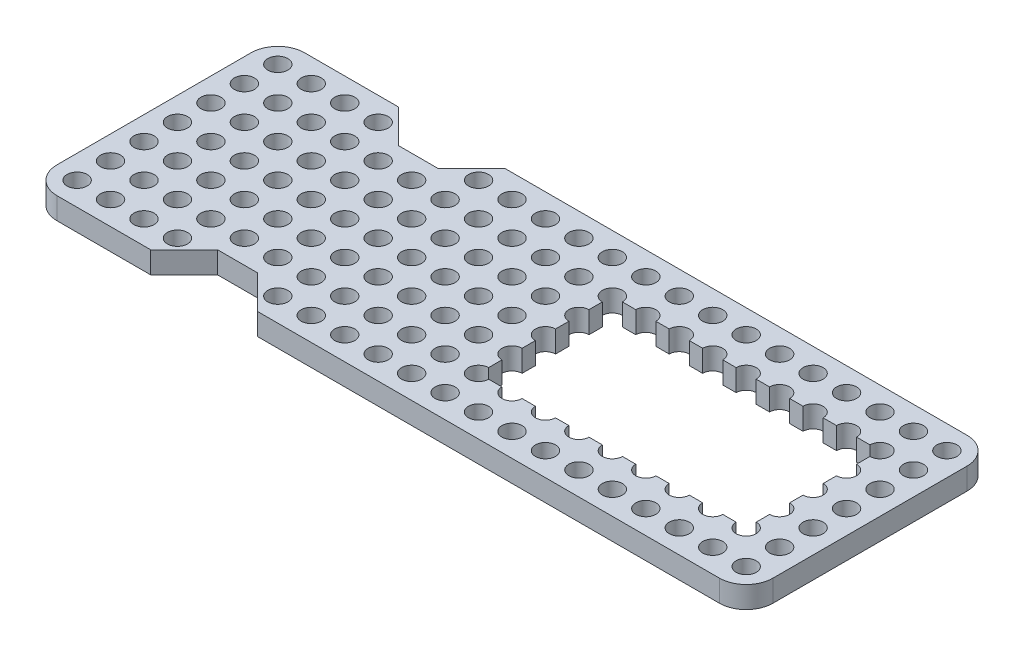
from build123d import *

# Parameters (mm, degrees)
SKETCH1_R           = 1.5025
BOSS_EXTRUDE1_DEPTH = 3.25


with BuildPart() as part:
    # Sketch1 → Boss-Extrude1 (new body)
    with BuildSketch(Plane(origin=(0, 0, 0), x_dir=(1, 0, 0), z_dir=(0, 1, 0))):
        with BuildLine():
            Line((-35.5, 18.5), (-49.5, 18.5))
            ThreePointArc((-49.5, 18.5), (-52.328427125, 17.328427125), (-53.5, 14.5))
            Line((-53.5, 14.5), (-53.5, -14.5))
            ThreePointArc((-53.5, -14.5), (-52.328427125, -17.328427125), (-49.5, -18.5))
            Line((-49.5, -18.5), (-35.5, -18.5))
            Line((-35.5, -18.5), (-30.5, -13.5))
            Line((-30.5, -13.5), (-24.913361383, -13.5))
            Line((-24.913361383, -13.5), (-24.5, -13.5))
            Line((-24.5, -13.5), (-24.358821857, -13.641178143))
            Line((-24.358821857, -13.641178143), (-19.5, -18.5))
            Line((-19.5, -18.5), (49.5, -18.5))
            ThreePointArc((49.5, -18.5), (52.328427125, -17.328427125), (53.5, -14.5))
            Line((53.5, -14.5), (53.5, 14.5))
            ThreePointArc((53.5, 14.5), (52.328427125, 17.328427125), (49.5, 18.5))
            Line((49.5, 18.5), (-19.5, 18.5))
            Line((-19.5, 18.5), (-24.358821857, 13.641178143))
            Line((-24.358821857, 13.641178143), (-24.5, 13.5))
            Line((-24.5, 13.5), (-24.913361383, 13.5))
            Line((-24.913361383, 13.5), (-30.086638617, 13.5))
            Line((-30.086638617, 13.5), (-30.5, 13.5))
            Line((-30.5, 13.5), (-30.641178143, 13.641178143))
            Line((-30.641178143, 13.641178143), (-35.5, 18.5))
        make_face()
        with Locations((-50, -15)):
            Circle(SKETCH1_R, mode=Mode.SUBTRACT)
        with Locations((-45, -15)):
            Circle(SKETCH1_R, mode=Mode.SUBTRACT)
        with Locations((-40, -15)):
            Circle(SKETCH1_R, mode=Mode.SUBTRACT)
        with Locations((-35, -15)):
            Circle(SKETCH1_R, mode=Mode.SUBTRACT)
        with Locations((-50, -10)):
            Circle(SKETCH1_R, mode=Mode.SUBTRACT)
        with Locations((-45, -10)):
            Circle(SKETCH1_R, mode=Mode.SUBTRACT)
        with Locations((-40, -10)):
            Circle(SKETCH1_R, mode=Mode.SUBTRACT)
        with Locations((-35, -10)):
            Circle(SKETCH1_R, mode=Mode.SUBTRACT)
        with Locations((-30, -10)):
            Circle(SKETCH1_R, mode=Mode.SUBTRACT)
        with Locations((-20, -15)):
            Circle(SKETCH1_R, mode=Mode.SUBTRACT)
        with Locations((-15, -15)):
            Circle(SKETCH1_R, mode=Mode.SUBTRACT)
        with Locations((-10, -15)):
            Circle(SKETCH1_R, mode=Mode.SUBTRACT)
        with Locations((-5, -15)):
            Circle(SKETCH1_R, mode=Mode.SUBTRACT)
        with Locations((-25, -10)):
            Circle(SKETCH1_R, mode=Mode.SUBTRACT)
        with Locations((-20, -10)):
            Circle(SKETCH1_R, mode=Mode.SUBTRACT)
        with Locations((-15, -10)):
            Circle(SKETCH1_R, mode=Mode.SUBTRACT)
        with Locations((-10, -10)):
            Circle(SKETCH1_R, mode=Mode.SUBTRACT)
        with Locations((-5, -10)):
            Circle(SKETCH1_R, mode=Mode.SUBTRACT)
        with Locations((0, -10)):
            Circle(SKETCH1_R, mode=Mode.SUBTRACT)
        with Locations((-50, -5)):
            Circle(SKETCH1_R, mode=Mode.SUBTRACT)
        with Locations((-45, -5)):
            Circle(SKETCH1_R, mode=Mode.SUBTRACT)
        with Locations((-40, -5)):
            Circle(SKETCH1_R, mode=Mode.SUBTRACT)
        with Locations((-35, -5)):
            Circle(SKETCH1_R, mode=Mode.SUBTRACT)
        with Locations((-30, -5)):
            Circle(SKETCH1_R, mode=Mode.SUBTRACT)
        with Locations((-25, -5)):
            Circle(SKETCH1_R, mode=Mode.SUBTRACT)
        with Locations((-20, -5)):
            Circle(SKETCH1_R, mode=Mode.SUBTRACT)
        with Locations((-15, -5)):
            Circle(SKETCH1_R, mode=Mode.SUBTRACT)
        with Locations((-10, -5)):
            Circle(SKETCH1_R, mode=Mode.SUBTRACT)
        with Locations((-5, -5)):
            Circle(SKETCH1_R, mode=Mode.SUBTRACT)
        with Locations((0, -5)):
            Circle(SKETCH1_R, mode=Mode.SUBTRACT)
        with Locations((0, -15)):
            Circle(SKETCH1_R, mode=Mode.SUBTRACT)
        with Locations((5, -15)):
            Circle(SKETCH1_R, mode=Mode.SUBTRACT)
        with Locations((10, -15)):
            Circle(SKETCH1_R, mode=Mode.SUBTRACT)
        with Locations((15, -15)):
            Circle(SKETCH1_R, mode=Mode.SUBTRACT)
        with Locations((20, -15)):
            Circle(SKETCH1_R, mode=Mode.SUBTRACT)
        with Locations((25, -15)):
            Circle(SKETCH1_R, mode=Mode.SUBTRACT)
        with Locations((30, -15)):
            Circle(SKETCH1_R, mode=Mode.SUBTRACT)
        with Locations((35, -15)):
            Circle(SKETCH1_R, mode=Mode.SUBTRACT)
        with Locations((40, -15)):
            Circle(SKETCH1_R, mode=Mode.SUBTRACT)
        with Locations((45, -15)):
            Circle(SKETCH1_R, mode=Mode.SUBTRACT)
        with Locations((50, -15)):
            Circle(SKETCH1_R, mode=Mode.SUBTRACT)
        with Locations((50, -10)):
            Circle(SKETCH1_R, mode=Mode.SUBTRACT)
        with Locations((50, -5)):
            Circle(SKETCH1_R, mode=Mode.SUBTRACT)
        with Locations((-50, 0)):
            Circle(SKETCH1_R, mode=Mode.SUBTRACT)
        with Locations((-45, 0)):
            Circle(SKETCH1_R, mode=Mode.SUBTRACT)
        with Locations((-40, 0)):
            Circle(SKETCH1_R, mode=Mode.SUBTRACT)
        with Locations((-35, 0)):
            Circle(SKETCH1_R, mode=Mode.SUBTRACT)
        with Locations((-30, 0)):
            Circle(SKETCH1_R, mode=Mode.SUBTRACT)
        with Locations((-50, 5)):
            Circle(SKETCH1_R, mode=Mode.SUBTRACT)
        with Locations((-45, 5)):
            Circle(SKETCH1_R, mode=Mode.SUBTRACT)
        with Locations((-40, 5)):
            Circle(SKETCH1_R, mode=Mode.SUBTRACT)
        with Locations((-35, 5)):
            Circle(SKETCH1_R, mode=Mode.SUBTRACT)
        with Locations((-30, 5)):
            Circle(SKETCH1_R, mode=Mode.SUBTRACT)
        with Locations((-25, 0)):
            Circle(SKETCH1_R, mode=Mode.SUBTRACT)
        with Locations((-20, 0)):
            Circle(SKETCH1_R, mode=Mode.SUBTRACT)
        with Locations((-15, 0)):
            Circle(SKETCH1_R, mode=Mode.SUBTRACT)
        with Locations((-10, 0)):
            Circle(SKETCH1_R, mode=Mode.SUBTRACT)
        with Locations((-5, 0)):
            Circle(SKETCH1_R, mode=Mode.SUBTRACT)
        Circle(SKETCH1_R, mode=Mode.SUBTRACT)
        with Locations((-25, 5)):
            Circle(SKETCH1_R, mode=Mode.SUBTRACT)
        with Locations((-20, 5)):
            Circle(SKETCH1_R, mode=Mode.SUBTRACT)
        with Locations((-15, 5)):
            Circle(SKETCH1_R, mode=Mode.SUBTRACT)
        with Locations((-10, 5)):
            Circle(SKETCH1_R, mode=Mode.SUBTRACT)
        with Locations((-5, 5)):
            Circle(SKETCH1_R, mode=Mode.SUBTRACT)
        with Locations((0, 5)):
            Circle(SKETCH1_R, mode=Mode.SUBTRACT)
        with Locations((-50, 10)):
            Circle(SKETCH1_R, mode=Mode.SUBTRACT)
        with Locations((-45, 10)):
            Circle(SKETCH1_R, mode=Mode.SUBTRACT)
        with Locations((-40, 10)):
            Circle(SKETCH1_R, mode=Mode.SUBTRACT)
        with Locations((-35, 10)):
            Circle(SKETCH1_R, mode=Mode.SUBTRACT)
        with Locations((-30, 10)):
            Circle(SKETCH1_R, mode=Mode.SUBTRACT)
        with Locations((-50, 15)):
            Circle(SKETCH1_R, mode=Mode.SUBTRACT)
        with Locations((-45, 15)):
            Circle(SKETCH1_R, mode=Mode.SUBTRACT)
        with Locations((-40, 15)):
            Circle(SKETCH1_R, mode=Mode.SUBTRACT)
        with Locations((-35, 15)):
            Circle(SKETCH1_R, mode=Mode.SUBTRACT)
        with Locations((-25, 10)):
            Circle(SKETCH1_R, mode=Mode.SUBTRACT)
        with Locations((-20, 10)):
            Circle(SKETCH1_R, mode=Mode.SUBTRACT)
        with Locations((-15, 10)):
            Circle(SKETCH1_R, mode=Mode.SUBTRACT)
        with Locations((-10, 10)):
            Circle(SKETCH1_R, mode=Mode.SUBTRACT)
        with Locations((-5, 10)):
            Circle(SKETCH1_R, mode=Mode.SUBTRACT)
        with Locations((0, 10)):
            Circle(SKETCH1_R, mode=Mode.SUBTRACT)
        with Locations((-20, 15)):
            Circle(SKETCH1_R, mode=Mode.SUBTRACT)
        with Locations((-15, 15)):
            Circle(SKETCH1_R, mode=Mode.SUBTRACT)
        with Locations((-10, 15)):
            Circle(SKETCH1_R, mode=Mode.SUBTRACT)
        with Locations((-5, 15)):
            Circle(SKETCH1_R, mode=Mode.SUBTRACT)
        with Locations((0, 15)):
            Circle(SKETCH1_R, mode=Mode.SUBTRACT)
        with BuildLine():
            Line((45, -6.5025), (45, -8.4975))
            ThreePointArc((45, -8.4975), (46.062427939, -11.062427939), (43.4975, -10))
            Line((43.4975, -10), (41.5025, -10))
            ThreePointArc((41.5025, -10), (40, -11.5025), (38.4975, -10))
            Line((38.4975, -10), (36.5025, -10))
            ThreePointArc((36.5025, -10), (35, -11.5025), (33.4975, -10))
            Line((33.4975, -10), (31.5025, -10))
            ThreePointArc((31.5025, -10), (30, -11.5025), (28.4975, -10))
            Line((28.4975, -10), (26.5025, -10))
            ThreePointArc((26.5025, -10), (25, -11.5025), (23.4975, -10))
            Line((23.4975, -10), (21.5025, -10))
            ThreePointArc((21.5025, -10), (20, -11.5025), (18.4975, -10))
            Line((18.4975, -10), (16.5025, -10))
            ThreePointArc((16.5025, -10), (15, -11.5025), (13.4975, -10))
            Line((13.4975, -10), (11.5025, -10))
            ThreePointArc((11.5025, -10), (10, -11.5025), (8.4975, -10))
            Line((8.4975, -10), (6.5025, -10))
            ThreePointArc((6.5025, -10), (3.937572061, -11.062427939), (5, -8.4975))
            Line((5, -8.4975), (5, -6.5025))
            ThreePointArc((5, -6.5025), (3.4975, -5), (5, -3.4975))
            Line((5, -3.4975), (5, -1.5025))
            ThreePointArc((5, -1.5025), (3.4975, 0), (5, 1.5025))
            Line((5, 1.5025), (5, 3.4975))
            ThreePointArc((5, 3.4975), (3.4975, 5), (5, 6.5025))
            Line((5, 6.5025), (5, 8.4975))
            ThreePointArc((5, 8.4975), (3.937572061, 11.062427939), (6.5025, 10))
            Line((6.5025, 10), (8.4975, 10))
            ThreePointArc((8.4975, 10), (10, 11.5025), (11.5025, 10))
            Line((11.5025, 10), (13.4975, 10))
            ThreePointArc((13.4975, 10), (15, 11.5025), (16.5025, 10))
            Line((16.5025, 10), (18.4975, 10))
            ThreePointArc((18.4975, 10), (20, 11.5025), (21.5025, 10))
            Line((21.5025, 10), (23.4975, 10))
            ThreePointArc((23.4975, 10), (25, 11.5025), (26.5025, 10))
            Line((26.5025, 10), (28.4975, 10))
            ThreePointArc((28.4975, 10), (30, 11.5025), (31.5025, 10))
            Line((31.5025, 10), (33.4975, 10))
            ThreePointArc((33.4975, 10), (35, 11.5025), (36.5025, 10))
            Line((36.5025, 10), (38.4975, 10))
            ThreePointArc((38.4975, 10), (40, 11.5025), (41.5025, 10))
            Line((41.5025, 10), (43.4975, 10))
            ThreePointArc((43.4975, 10), (46.062427939, 11.062427939), (45, 8.4975))
            Line((45, 8.4975), (45, 6.5025))
            ThreePointArc((45, 6.5025), (46.5025, 5), (45, 3.4975))
            Line((45, 3.4975), (45, 1.5025))
            ThreePointArc((45, 1.5025), (46.5025, 0), (45, -1.5025))
            Line((45, -1.5025), (45, -3.4975))
            ThreePointArc((45, -3.4975), (46.5025, -5), (45, -6.5025))
        make_face(mode=Mode.SUBTRACT)
        with Locations((50, 0)):
            Circle(SKETCH1_R, mode=Mode.SUBTRACT)
        with Locations((50, 5)):
            Circle(SKETCH1_R, mode=Mode.SUBTRACT)
        with Locations((5, 15)):
            Circle(SKETCH1_R, mode=Mode.SUBTRACT)
        with Locations((10, 15)):
            Circle(SKETCH1_R, mode=Mode.SUBTRACT)
        with Locations((15, 15)):
            Circle(SKETCH1_R, mode=Mode.SUBTRACT)
        with Locations((20, 15)):
            Circle(SKETCH1_R, mode=Mode.SUBTRACT)
        with Locations((25, 15)):
            Circle(SKETCH1_R, mode=Mode.SUBTRACT)
        with Locations((50, 10)):
            Circle(SKETCH1_R, mode=Mode.SUBTRACT)
        with Locations((30, 15)):
            Circle(SKETCH1_R, mode=Mode.SUBTRACT)
        with Locations((35, 15)):
            Circle(SKETCH1_R, mode=Mode.SUBTRACT)
        with Locations((40, 15)):
            Circle(SKETCH1_R, mode=Mode.SUBTRACT)
        with Locations((45, 15)):
            Circle(SKETCH1_R, mode=Mode.SUBTRACT)
        with Locations((50, 15)):
            Circle(SKETCH1_R, mode=Mode.SUBTRACT)
    extrude(amount=BOSS_EXTRUDE1_DEPTH)


solid = part.part
